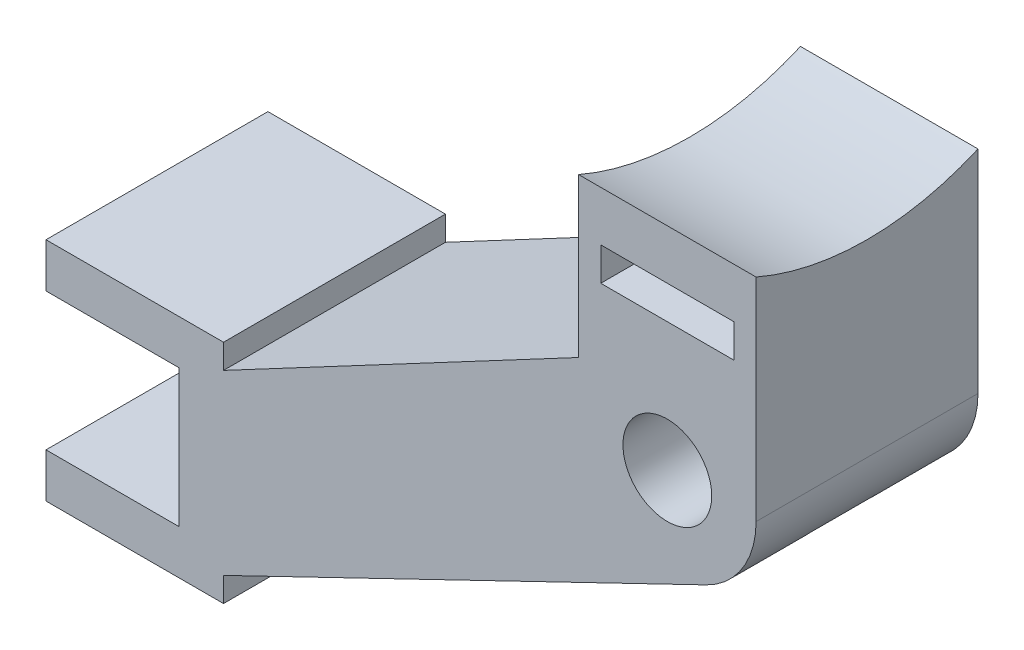
from build123d import *

# Parameters (mm, degrees)
ESBO_O1_R                = 2
ESBO_O1_W                = 6
ESBO_O1_H                = 1.5
RESSALTO_EXTRUS_O1_DEPTH = 10
RESSALTO_EXTRUS_O4_START = -4
RESSALTO_EXTRUS_O4_DEPTH = 8
CORTE_EXTRUS_O1_START    = -5.890675
ESBO_O3_W                = 6
ESBO_O3_H                = 3
CORTE_EXTRUS_O1_DEPTH    = 9.890675


with BuildPart() as part:
    # Esboço1 → Ressalto-extrusão1 (new body)
    with BuildSketch(Plane.XY):
        with BuildLine():
            Line((-28, -7), (-22, -7))
            Line((-22, -7), (-22, -13.2))
            Line((-22, -13.2), (-28, -13.2))
            Line((-28, -13.2), (-28, -15.2))
            Line((-28, -15.2), (-20, -15.2))
            Line((-20, -15.2), (-20, -14.1))
            Line((-20, -14.1), (1.739413567, -3.602005059))
            ThreePointArc((1.739413567, -3.602005059), (3.388041784, -2.12630498), (4, 0))
            Line((4, 0), (4, 8))
            Line((4, 8), (-4, 8))
            Line((-4, 8), (-4, 2.403900213))
            Line((-4, 2.403900213), (-20, -6.1))
            Line((-20, -6.1), (-20, -5))
            Line((-20, -5), (-28, -5))
            Line((-28, -5), (-28, -7))
        make_face()
        Circle(ESBO_O1_R, mode=Mode.SUBTRACT)
        with Locations((0, 6.55)):
            Rectangle(ESBO_O1_W, ESBO_O1_H, mode=Mode.SUBTRACT)
    extrude(amount=RESSALTO_EXTRUS_O1_DEPTH)

    # Esboço2 → Ressalto-extrusão4 (add)
    with BuildSketch(Plane(origin=(0, 0, 0), x_dir=(0, 0, -1), z_dir=(1, 0, 0)).offset(RESSALTO_EXTRUS_O4_START)):
        with BuildLine():
            ThreePointArc((-10, 9.543560763), (-5, 8.5), (0, 9.543560763))
            Line((0, 9.543560763), (0, 8))
            Line((0, 8), (-10, 8))
            Line((-10, 8), (-10, 9.543560763))
        make_face()
    extrude(amount=RESSALTO_EXTRUS_O4_DEPTH)

    # Esboço3 → Corte-extrusão1 (cut)
    with BuildSketch(Plane(origin=(0, 0, 0), x_dir=(1, 0, 0), z_dir=(0, 1, 0)).offset(CORTE_EXTRUS_O1_START)):
        with Locations((0, -5)):
            Rectangle(ESBO_O3_W, ESBO_O3_H)
    extrude(amount=CORTE_EXTRUS_O1_DEPTH, mode=Mode.SUBTRACT)


solid = part.part
